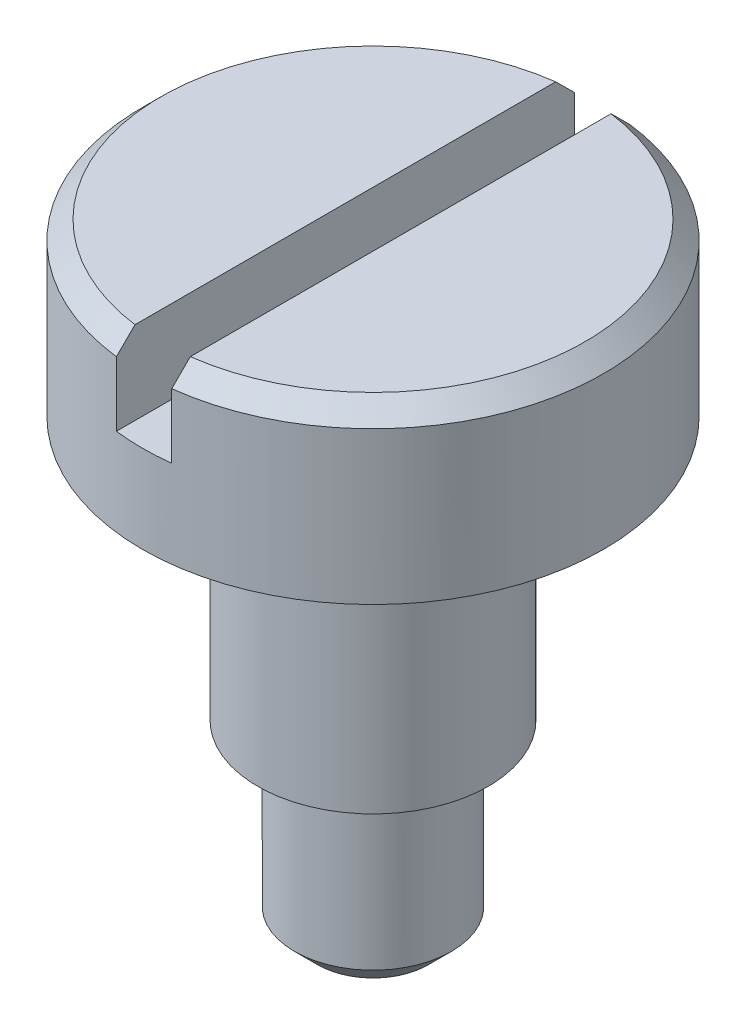
from build123d import *

# Parameters (mm, degrees)
SKETCH1_R               = 2.5
BOSS_EXTRUDE1_DEPTH     = 6.7
SKETCH2_OUTSIDE_W       = 8.948
SKETCH2_OUTSIDE_H       = 8.948
SKETCH2_OUTSIDE_R       = 0.85
CUT_EXTRUDE1_DEPTH      = 2
SKETCH3_OUTSIDE_W       = 8.948
SKETCH3_OUTSIDE_H       = 8.948
SKETCH3_OUTSIDE_R       = 1.25
CUT_EXTRUDE2_DEPTH      = 2.85
CHAMFER1_SIZE           = 0.2
SKETCH4_W               = 0.6
SKETCH4_H               = 0.9
CUT_EXTRUDE3_DEPTH      = 3.5
CUT_EXTRUDE3_DEPTH_BACK = 3.5
CHAMFER2_SIZE           = 0.25
FILLET1_R               = 0.1


with BuildPart() as part:
    # Sketch1 → Boss-Extrude1 (new body)
    with BuildSketch(Plane(origin=(0, 0, 0), x_dir=(1, 0, 0), z_dir=(0, 1, 0))):
        Circle(SKETCH1_R)
    extrude(amount=BOSS_EXTRUDE1_DEPTH)

    # Sketch2 outside → Cut-Extrude1 (cut)
    with BuildSketch(Plane.XZ):
        Rectangle(SKETCH2_OUTSIDE_W, SKETCH2_OUTSIDE_H)
        Circle(SKETCH2_OUTSIDE_R, mode=Mode.SUBTRACT)
    extrude(amount=-CUT_EXTRUDE1_DEPTH, mode=Mode.SUBTRACT)

    # Sketch3 outside → Cut-Extrude2 (cut)
    with BuildSketch(Plane.XZ.offset(-2)):
        Rectangle(SKETCH3_OUTSIDE_W, SKETCH3_OUTSIDE_H)
        Circle(SKETCH3_OUTSIDE_R, mode=Mode.SUBTRACT)
    extrude(amount=-CUT_EXTRUDE2_DEPTH, mode=Mode.SUBTRACT)

    # Chamfer1
    chamfer1_edges = [part.edges().sort_by_distance(p)[0] for p in [
        (-2.5, 6.7, 0),
    ]]
    chamfer(chamfer1_edges, length=CHAMFER1_SIZE)

    # Sketch4 → Cut-Extrude3 (cut, two sides)
    with BuildSketch(Plane.XY) as cut_extrude3_sk:
        with Locations((0, 6.25)):
            Rectangle(SKETCH4_W, SKETCH4_H)
    extrude(amount=CUT_EXTRUDE3_DEPTH, mode=Mode.SUBTRACT)
    extrude(cut_extrude3_sk.sketch, amount=-CUT_EXTRUDE3_DEPTH_BACK, mode=Mode.SUBTRACT)

    # Chamfer2
    chamfer2_edges = [part.edges().sort_by_distance(p)[0] for p in [
        (-0.85, 0, 0),
    ]]
    chamfer(chamfer2_edges, length=CHAMFER2_SIZE)

    # Fillet1
    fillet1_edges = [part.edges().sort_by_distance(p)[0] for p in [
        (-1.25, 4.85, 0),
    ]]
    fillet(fillet1_edges, radius=FILLET1_R)


solid = part.part
